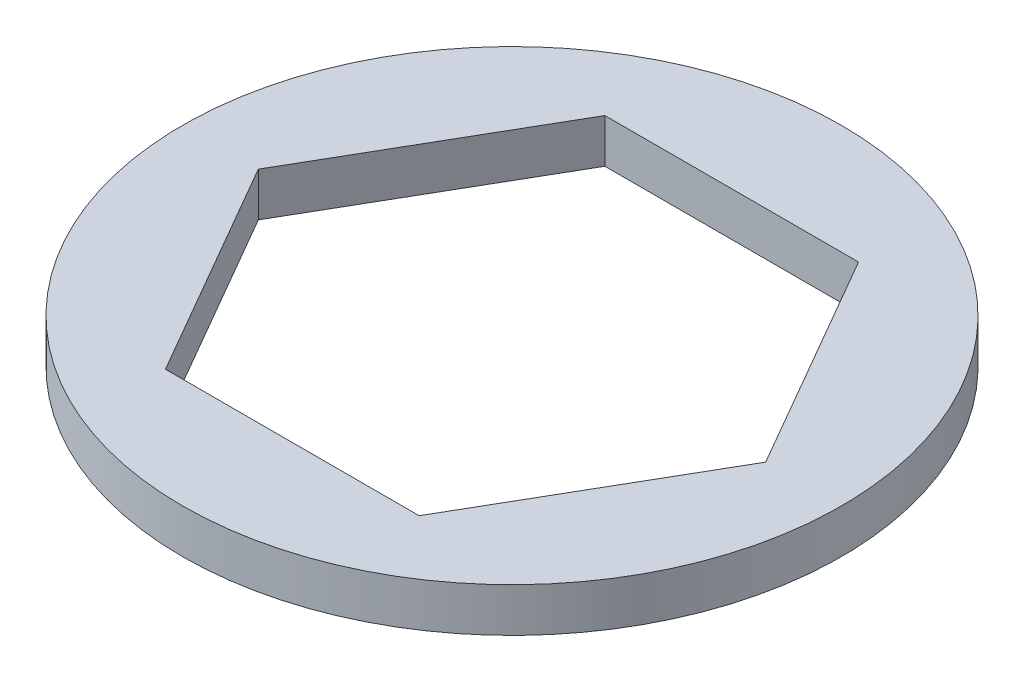
from build123d import *

# Parameters (mm, degrees)
SKETCH1_R           = 9.525
BOSS_EXTRUDE1_DEPTH = 1.27


with BuildPart() as part:
    # Sketch1 → Boss-Extrude1 (new body)
    with BuildSketch(Plane(origin=(0, 0, 0), x_dir=(1, 0, 0), z_dir=(0, 1, 0))):
        Circle(SKETCH1_R)
        Polygon((3.666174209, 6.35), (-3.666174209, 6.35), (-7.332348419, 0), (-3.666174209, -6.35), (3.666174209, -6.35), (7.332348419, 0), align=None, mode=Mode.SUBTRACT)
    extrude(amount=BOSS_EXTRUDE1_DEPTH)


solid = part.part
